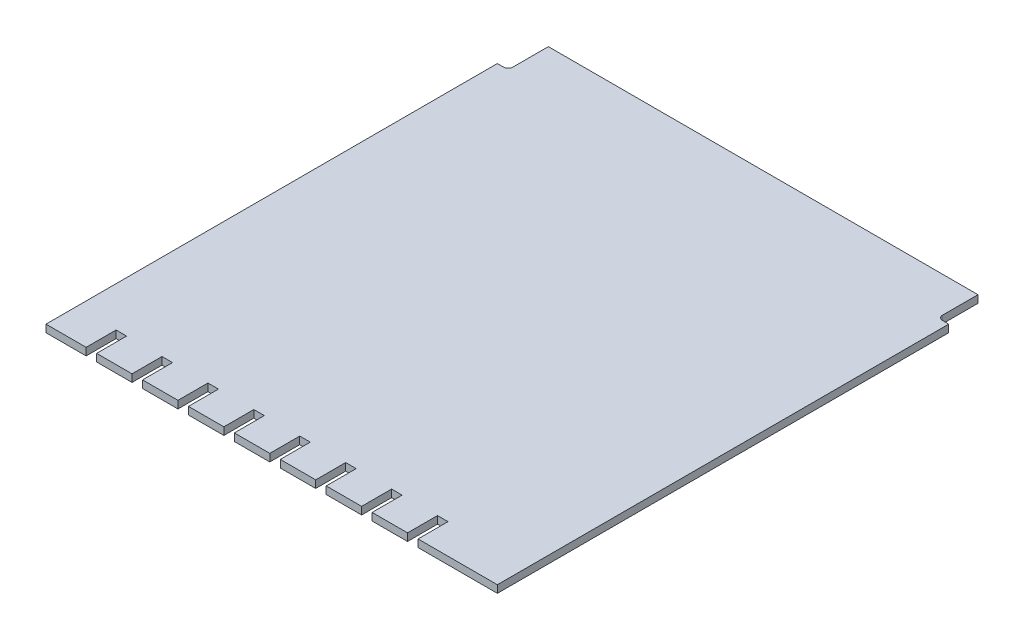
from build123d import *

# Parameters (mm, degrees)
BOSS_EXTRUDE1_DEPTH = 1.5875


with BuildPart() as part:
    # Sketch1 → Boss-Extrude1 (new body)
    with BuildSketch(Plane(origin=(0, 0, 0), x_dir=(1, 0, 0), z_dir=(0, 1, 0))):
        with BuildLine():
            Line((4.5, 96.6), (4.5, 104.1))
            Line((4.5, 104.1), (95.5, 104.1))
            Line((95.5, 104.1), (95.5, 96.6))
            ThreePointArc((95.5, 96.6), (95.792893219, 95.892893219), (96.5, 95.6))
            Line((96.5, 95.6), (97.8, 95.6))
            Line((97.8, 95.6), (97.8, 0))
            Line((97.8, 0), (81, 0))
            Line((81, 0), (81, 6.344902398))
            Line((81, 6.344902398), (78.775, 6.344902398))
            Line((78.775, 6.344902398), (78.775, 0))
            Line((78.775, 0), (71.275, 0))
            Line((71.275, 0), (71.275, 6.344902398))
            Line((71.275, 6.344902398), (69.05, 6.344902398))
            Line((69.05, 6.344902398), (69.05, 0))
            Line((69.05, 0), (61.55, 0))
            Line((61.55, 0), (61.55, 6.344902398))
            Line((61.55, 6.344902398), (59.325, 6.344902398))
            Line((59.325, 6.344902398), (59.325, 0))
            Line((59.325, 0), (51.825, 0))
            Line((51.825, 0), (51.825, 6.344902398))
            Line((51.825, 6.344902398), (49.6, 6.344902398))
            Line((49.6, 6.344902398), (49.6, 0))
            Line((49.6, 0), (42.1, 0))
            Line((42.1, 0), (42.1, 6.344902398))
            Line((42.1, 6.344902398), (39.875, 6.344902398))
            Line((39.875, 6.344902398), (39.875, 0))
            Line((39.875, 0), (32.375, 0))
            Line((32.375, 0), (32.375, 6.344902398))
            Line((32.375, 6.344902398), (30.15, 6.344902398))
            Line((30.15, 6.344902398), (30.15, 0))
            Line((30.15, 0), (22.65, 0))
            Line((22.65, 0), (22.65, 6.344902398))
            Line((22.65, 6.344902398), (20.425, 6.344902398))
            Line((20.425, 6.344902398), (20.425, 0))
            Line((20.425, 0), (12.925, 0))
            Line((12.925, 0), (12.925, 6.344902398))
            Line((12.925, 6.344902398), (10.7, 6.344902398))
            Line((10.7, 6.344902398), (10.7, 0))
            Line((10.7, 0), (2.2, 0))
            Line((2.2, 0), (2.2, 95.6))
            Line((2.2, 95.6), (3.5, 95.6))
            ThreePointArc((3.5, 95.6), (4.207106781, 95.892893219), (4.5, 96.6))
        make_face()
    extrude(amount=BOSS_EXTRUDE1_DEPTH)


solid = part.part
